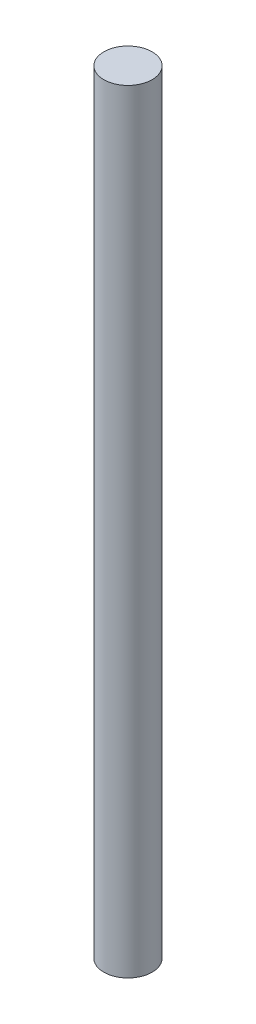
from build123d import *

# Parameters (mm, degrees)
SKETCH1_R           = 7.9375
BOSS_EXTRUDE1_DEPTH = 254


with BuildPart() as part:
    # Sketch1 → Boss-Extrude1 (new body)
    with BuildSketch(Plane(origin=(0, 0, 0), x_dir=(1, 0, 0), z_dir=(0, 1, 0))):
        Circle(SKETCH1_R)
    extrude(amount=BOSS_EXTRUDE1_DEPTH)


solid = part.part
